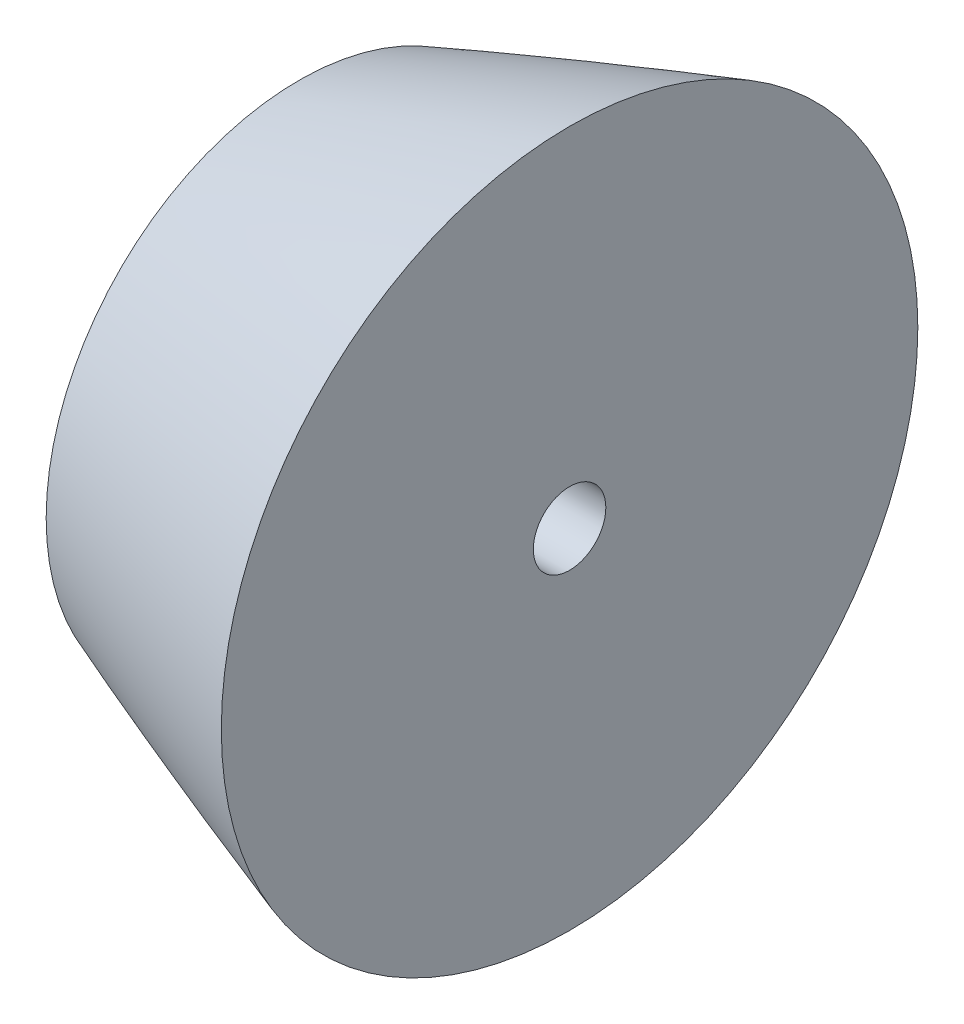
from build123d import *

# Parameters (mm, degrees)
SKETCH4_R               = 95.25
CUT_EXTRUDE2_DEPTH      = 439.670222351
SKETCH2_R               = 95.25
CUT_EXTRUDE3_DEPTH      = 50.173367204
F_1_4_20_TAPPED_HOLE1_D = 5.1054


with BuildPart() as part:
    # Sketch1 → Revolve3 (revolve)
    with BuildSketch(Plane.XY, mode=Mode.PRIVATE) as revolve3_sk:
        with BuildLine():
            Line((0, 0), (457.2, 0))
            Line((457.2, 0), (471.392765137, 0))
            Line((471.392765137, 0), (471.392765137, 95.25))
            Line((471.392765137, 95.25), (457.2, 95.25))
            add(Edge.make_bspline(
                [(0, 0), (0.002261413, 0.012559634), (0.008229149, 0.03727132), (0.026197477, 0.085010802), (0.070593088, 0.176725307), (0.135390602, 0.284235785), (0.220401303, 0.406590084), (0.336037993, 0.556544126), (0.508304998, 0.760811711), (0.80208614, 1.073293742), (1.325080854, 1.565169332), (2.238118633, 2.319225256), (3.825271995, 3.466618443), (6.613989832, 5.225294798), (11.456120137, 7.876617711), (19.293604572, 11.601746405), (32.615554098, 17.130480015), (51.688271319, 23.981890995), (75.613057969, 31.54621241), (103.310212008, 39.361975261), (131.892371678, 46.686426538), (160.614305524, 53.440297164), (189.44815344, 59.696867207), (218.376688059, 65.499444524), (247.387631707, 70.874021631), (276.472706829, 75.831796355), (305.625866717, 80.372187528), (334.843049411, 84.481216859), (364.121565724, 88.129371268), (389.792768776, 90.870557363), (411.834102605, 92.837355417), (428.995077346, 94.067568174), (440.032338735, 94.69756489), (448.618051981, 95.062046142), (453.521410507, 95.200160943), (455.973700484, 95.244255862), (457.2, 95.25)],
                knots=[0, 0, 0, 0, 0, 0.000108244, 0.000216487, 0.000432974, 0.000865949, 0.001174715, 0.001483481, 0.002043604, 0.003138685, 0.004821522, 0.007588035, 0.012111566, 0.019790706, 0.032854349, 0.05452956, 0.085906528, 0.142462243, 0.205216412, 0.267970588, 0.330724763, 0.393478942, 0.456233118, 0.518987298, 0.581741474, 0.644495652, 0.707249831, 0.770004011, 0.832758189, 0.895512367, 0.926889456, 0.958266545, 0.979133273, 0.989566636, 1, 1, 1, 1, 1], degree=4))
        make_face()
    revolve(revolve3_sk.sketch.rotate(Axis((0, 0, 0), (1, 0, 0)), 90), axis=Axis((0, 0, 0), (1, 0, 0)))

    # Sketch4 → Cut-Extrude2 (cut, through all)
    with BuildSketch(Plane(origin=(53.916491633, 0, 0), x_dir=(0, 0, -1), z_dir=(1, 0, 0))):
        Circle(SKETCH4_R)
    extrude(amount=CUT_EXTRUDE2_DEPTH, mode=Mode.SUBTRACT)

    # Sketch2 → Cut-Extrude3 (cut, through all)
    with BuildSketch(Plane(origin=(34.866491633, 0, 0), x_dir=(0, 0, -1), z_dir=(1, 0, 0))):
        Circle(SKETCH2_R)
    extrude(amount=-CUT_EXTRUDE3_DEPTH, mode=Mode.SUBTRACT)

    # 1/4-20 Tapped Hole1 (through all)
    with Locations(Plane(origin=(53.916491633, 0, 0), x_dir=(0, 0, -1), z_dir=(1, 0, 0))):
        with Locations((0, 0)):
            Hole(F_1_4_20_TAPPED_HOLE1_D / 2)


solid = part.part
